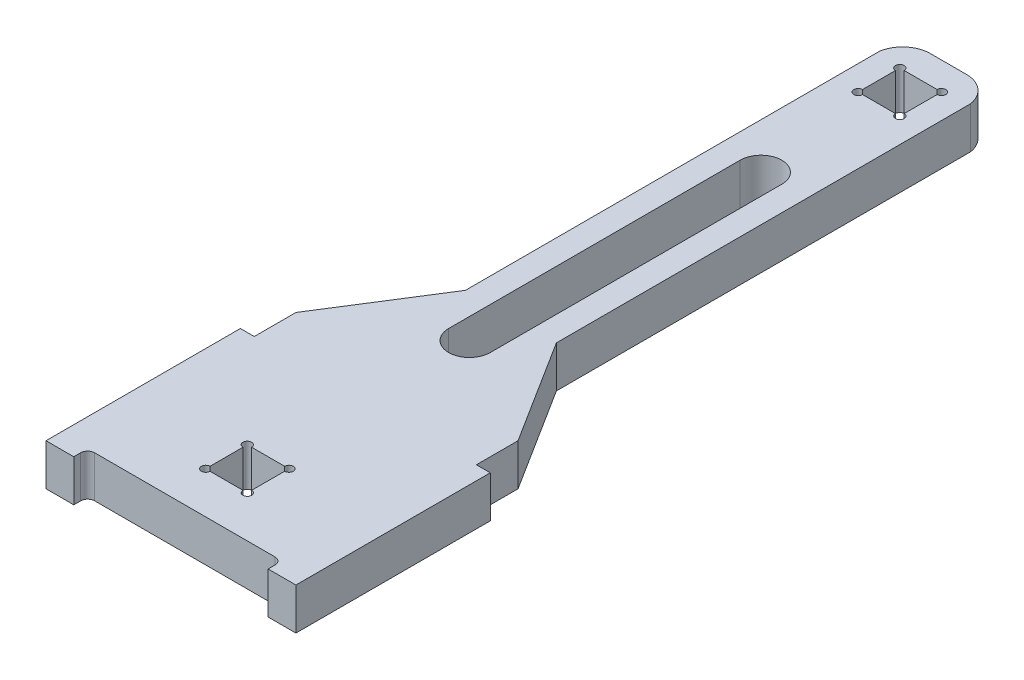
from build123d import *

# Parameters (mm, degrees)
SKETCH1_W                       = 9.525
SKETCH1_H                       = 9.525
BOSS_EXTRUDE1_DEPTH             = 9.525
CUT_EXTRUDE2_DEPTH              = 10.525
CUT_EXTRUDE3_DEPTH              = 10.525
F_5_64_0_07813_DIAMETER_HOLE1_D = 1.984502


with BuildPart() as part:
    # Sketch1 → Boss-Extrude1 (new body)
    with BuildSketch(Plane(origin=(0, 0, 0), x_dir=(1, 0, 0), z_dir=(0, 1, 0))):
        with BuildLine():
            Line((-4.138568073, 94.60926025), (4.138568073, 94.60926025))
            ThreePointArc((4.138568073, 94.60926025), (8.245532024, 93.102332324), (10.40323655, 89.29677115))
            Line((10.40323655, 89.29677115), (10.40323655, -5.448440201))
            Line((10.40323655, -5.448440201), (25.4, -29.21573975))
            Line((25.4, -29.21573975), (25.4, -38.74073975))
            Line((25.4, -38.74073975), (28.575, -38.74073975))
            Line((28.575, -38.74073975), (28.575, -83.19073975))
            Line((28.575, -83.19073975), (-28.575, -83.19073975))
            Line((-28.575, -83.19073975), (-28.575, -38.74073975))
            Line((-28.575, -38.74073975), (-25.4, -38.74073975))
            Line((-25.4, -38.74073975), (-25.4, -29.21573975))
            Line((-25.4, -29.21573975), (-10.40323655, -5.448440201))
            Line((-10.40323655, -5.448440201), (-10.40323655, 89.29677115))
            ThreePointArc((-10.40323655, 89.29677115), (-8.245532024, 93.102332324), (-4.138568073, 94.60926025))
        make_face()
        with Locations((0, -65.72823975)):
            Rectangle(SKETCH1_W, SKETCH1_H, mode=Mode.SUBTRACT)
        with Locations((0, 83.49676025)):
            Rectangle(SKETCH1_W, SKETCH1_H, mode=Mode.SUBTRACT)
    extrude(amount=BOSS_EXTRUDE1_DEPTH)

    # Sketch4 → Cut-Extrude2 (cut, through all)
    with BuildSketch(Plane(origin=(0, 9.525, 0), x_dir=(1, 0, 0), z_dir=(0, 1, 0))):
        with BuildLine():
            Line((4.7625, 51.74676025), (4.7625, -14.92823975))
            ThreePointArc((4.7625, -14.92823975), (0, -19.69073975), (-4.7625, -14.92823975))
            Line((-4.7625, -14.92823975), (-4.7625, 51.74676025))
            ThreePointArc((-4.7625, 51.74676025), (0, 56.50926025), (4.7625, 51.74676025))
        make_face()
    extrude(amount=-CUT_EXTRUDE2_DEPTH, mode=Mode.SUBTRACT)

    # Sketch5 → Cut-Extrude3 (cut, through all)
    with BuildSketch(Plane(origin=(0, 9.525, 0), x_dir=(1, 0, 0), z_dir=(0, 1, 0))):
        with BuildLine():
            Line((-22.225, -83.19073975), (22.225, -83.19073975))
            Line((22.225, -83.19073975), (22.225, -81.60323975))
            ThreePointArc((22.225, -81.60323975), (21.760032015, -80.480707734), (20.6375, -80.01573975))
            Line((20.6375, -80.01573975), (-20.6375, -80.01573975))
            ThreePointArc((-20.6375, -80.01573975), (-21.760032015, -80.480707734), (-22.225, -81.60323975))
            Line((-22.225, -81.60323975), (-22.225, -83.19073975))
        make_face()
    extrude(amount=-CUT_EXTRUDE3_DEPTH, mode=Mode.SUBTRACT)

    # 5/64 (0.07813) Diameter Hole1 (through all)
    with Locations(Plane(origin=(0, 9.525, 0), x_dir=(1, 0, 0), z_dir=(0, 1, 0))):
        with Locations((-4.7625, 88.25926025), (4.7625, 88.25926025), (4.7625, 78.73426025), (-4.7625, 78.73426025), (-4.7625, -60.96573975), (4.7625, -60.96573975), (4.7625, -70.49073975), (-4.7625, -70.49073975)):
            Hole(F_5_64_0_07813_DIAMETER_HOLE1_D / 2)


solid = part.part
